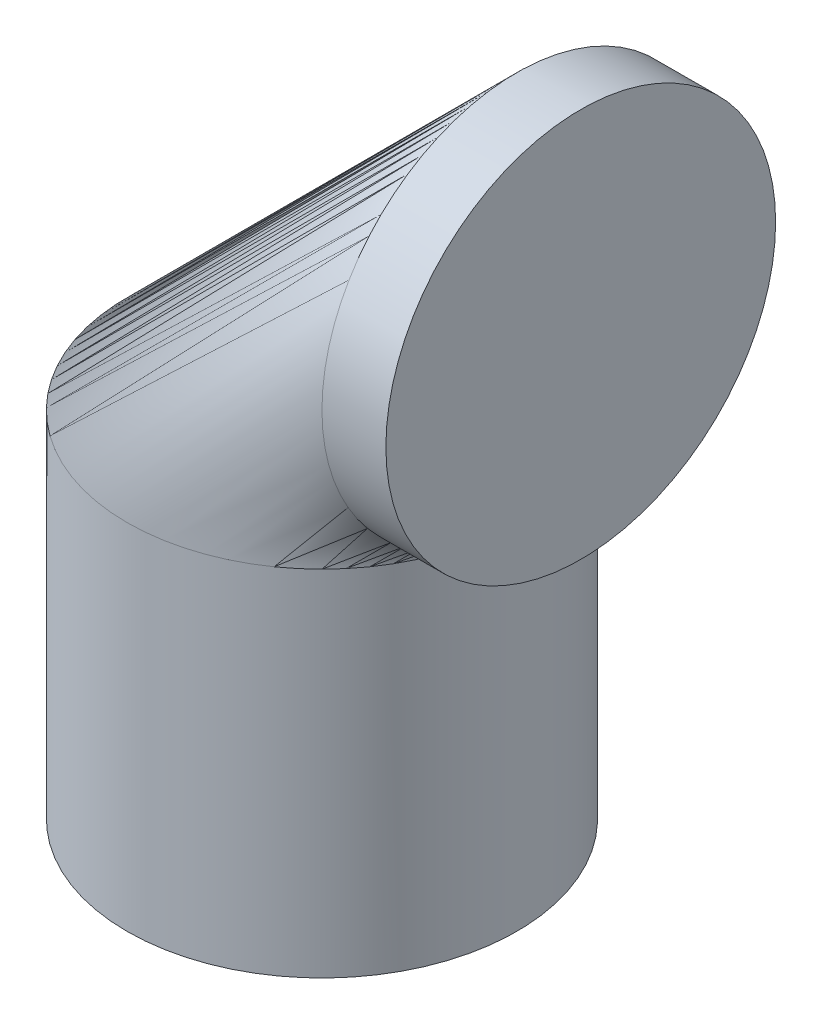
from build123d import *

# Parameters (mm, degrees)
SKETCH5_R = 25


with BuildPart() as part:
    # Sweep2: sweep along a path in Sketch4
    with BuildLine(Plane.XY) as sweep2_path:
        Line((0, 0), (0, 45.42))
        ThreePointArc((0, 45.42), (7.32233047, 63.09766953), (25, 70.42))
        Line((25, 70.42), (33.2, 70.42))
    # Sketch5 → Sweep2 (sweep)
    with BuildSketch(Plane(origin=(0, 0, 0), x_dir=(1, 0, 0), z_dir=(0, 1, 0))):
        Circle(SKETCH5_R)
    sweep(path=sweep2_path.line)


solid = part.part
